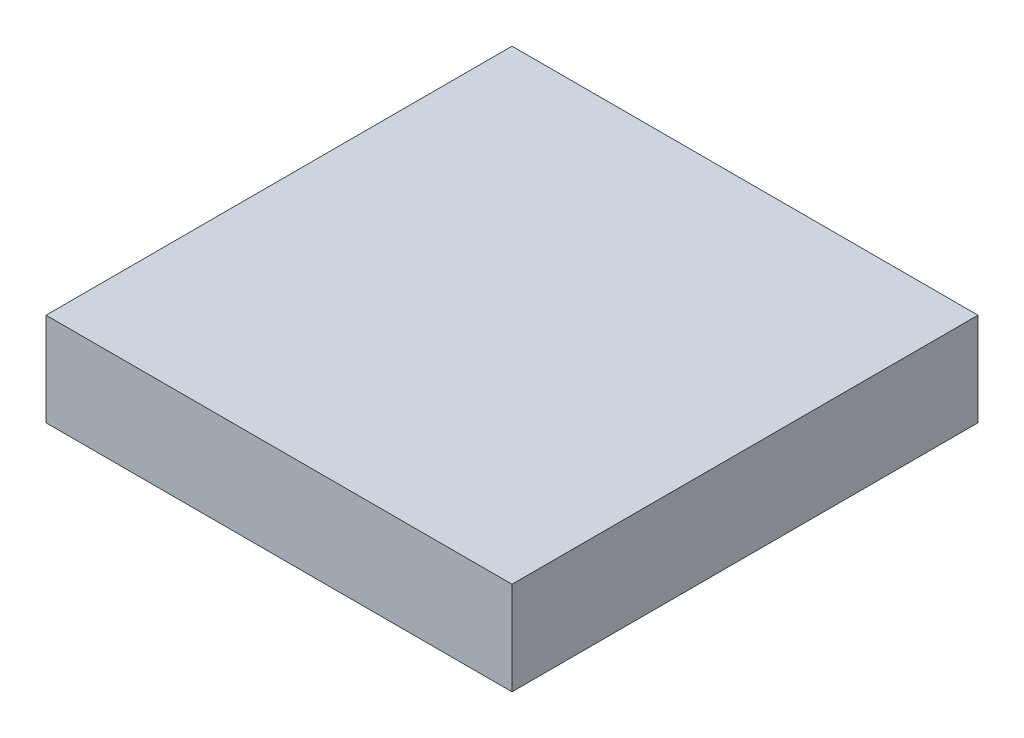
from build123d import *

# Parameters (mm, degrees)
SKETCH1_W           = 127
SKETCH1_H           = 127
BOSS_EXTRUDE1_DEPTH = 25.4


with BuildPart() as part:
    # Sketch1 → Boss-Extrude1 (new body)
    with BuildSketch(Plane(origin=(0, 0, 0), x_dir=(1, 0, 0), z_dir=(0, 1, 0))):
        Rectangle(SKETCH1_W, SKETCH1_H)
    extrude(amount=BOSS_EXTRUDE1_DEPTH)


solid = part.part
